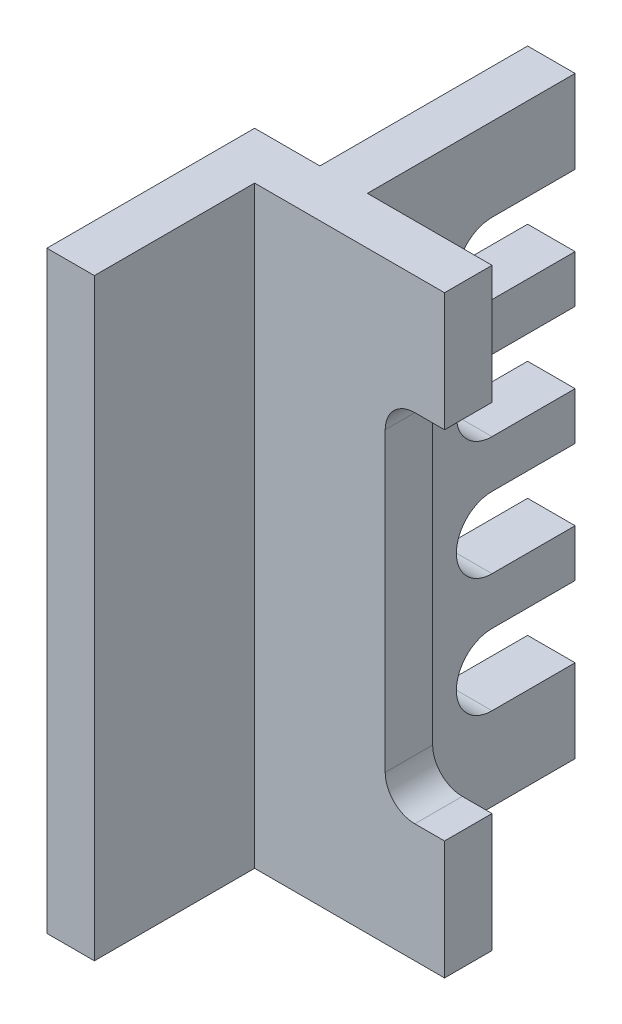
from build123d import *

# Parameters (mm, degrees)
BOSS_EXTRUDE1_DEPTH = 100
CUT_EXTRUDE1_DEPTH  = 8
SKETCH4_W           = 8
SKETCH4_H           = 100
BOSS_EXTRUDE2_DEPTH = 35
CUT_EXTRUDE2_DEPTH  = 8


with BuildPart() as part:
    # Sketch1 → Boss-Extrude1 (new body)
    with BuildSketch(Plane(origin=(0, 0, 0), x_dir=(1, 0, 0), z_dir=(0, 1, 0))):
        Polygon((0, 0), (8, 0), (8, 27), (40, 27), (40, 35), (0, 35), align=None)
    extrude(amount=BOSS_EXTRUDE1_DEPTH)

    # Sketch3 → Cut-Extrude1 (cut)
    with BuildSketch(Plane(origin=(0, 0, -35), x_dir=(-1, 0, 0), z_dir=(0, 0, -1))):
        with BuildLine():
            Line((-40, 20), (-35, 20))
            ThreePointArc((-35, 20), (-31.464466094, 21.464466094), (-30, 25))
            Line((-30, 25), (-30, 75))
            ThreePointArc((-30, 75), (-31.464466094, 78.535533906), (-35, 80))
            Line((-35, 80), (-40, 80))
            Line((-40, 80), (-40, 20))
        make_face()
    extrude(amount=-CUT_EXTRUDE1_DEPTH, mode=Mode.SUBTRACT)

    # Sketch4 → Boss-Extrude2 (add)
    with BuildSketch(Plane(origin=(0, 0, -35), x_dir=(-1, 0, 0), z_dir=(0, 0, -1))):
        with Locations((-15, 50)):
            Rectangle(SKETCH4_W, SKETCH4_H)
    extrude(amount=BOSS_EXTRUDE2_DEPTH)

    # Sketch5 → Cut-Extrude2 (cut)
    with BuildSketch(Plane(origin=(19, 0, 0), x_dir=(0, 0, -1), z_dir=(1, 0, 0))):
        with BuildLine():
            Line((56, 86), (70, 86))
            Line((70, 86), (70, 74))
            Line((70, 74), (56, 74))
            ThreePointArc((56, 74), (50, 80), (56, 86))
        make_face()
        with BuildLine():
            Line((70, 54), (56, 54))
            ThreePointArc((56, 54), (50, 60), (56, 66))
            Line((56, 66), (70, 66))
            Line((70, 66), (70, 54))
        make_face()
        with BuildLine():
            Line((70, 34), (56, 34))
            ThreePointArc((56, 34), (50, 40), (56, 46))
            Line((56, 46), (70, 46))
            Line((70, 46), (70, 34))
        make_face()
        with BuildLine():
            Line((70, 14), (56, 14))
            ThreePointArc((56, 14), (50, 20), (56, 26))
            Line((56, 26), (70, 26))
            Line((70, 26), (70, 14))
        make_face()
    extrude(amount=-CUT_EXTRUDE2_DEPTH, mode=Mode.SUBTRACT)


solid = part.part
